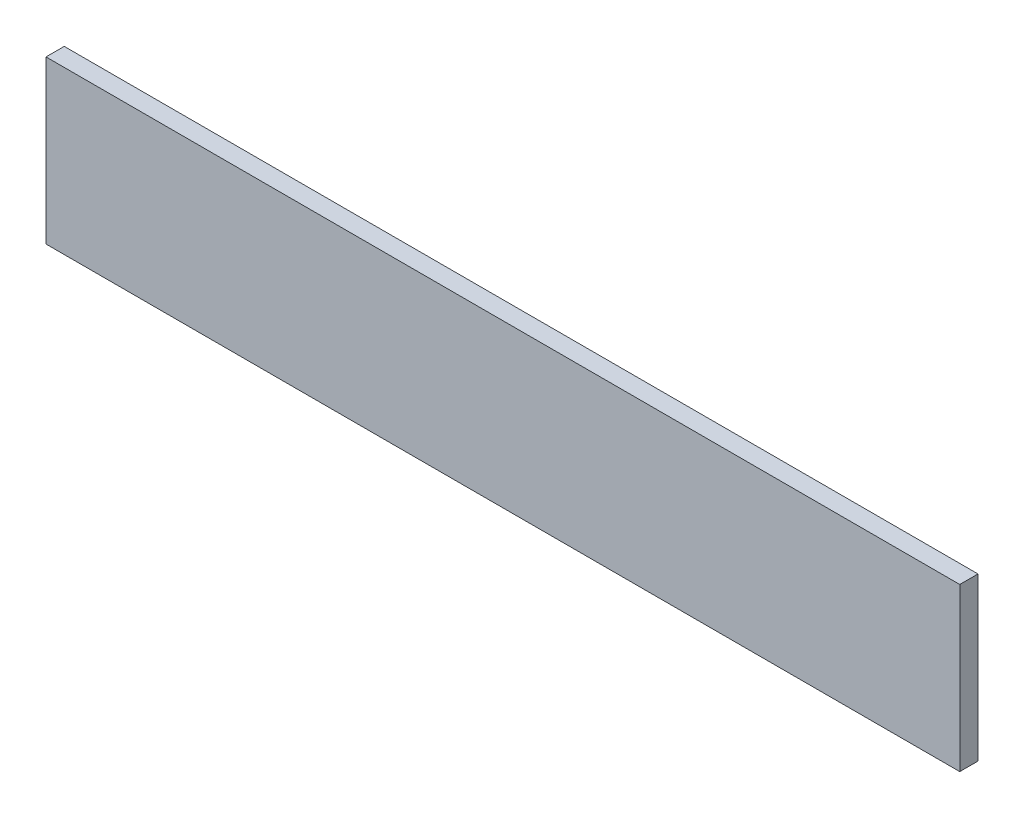
from build123d import *

# Parameters (mm, degrees)
SZKIC1_W                    = 451
SZKIC1_H                    = 80
DODANIE_WYCI_GNI_CIE1_DEPTH = 9


with BuildPart() as part:
    # Szkic1 → Dodanie-wyciągnięcie1 (new body)
    with BuildSketch(Plane.XY):
        with Locations((225.5, 40)):
            Rectangle(SZKIC1_W, SZKIC1_H)
    extrude(amount=-DODANIE_WYCI_GNI_CIE1_DEPTH)


solid = part.part
